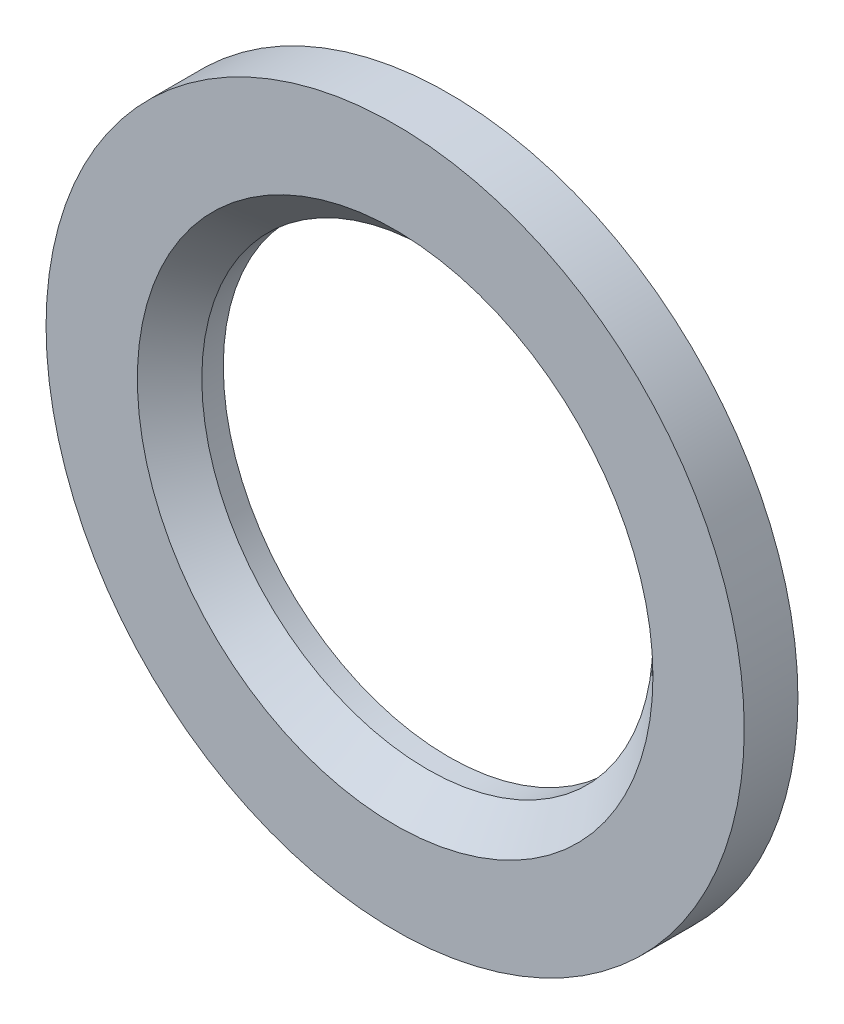
from build123d import *

# Parameters (mm, degrees)
SKETCH1_R           = 6.5
SKETCH1_R_2         = 4.2
BOSS_EXTRUDE1_DEPTH = 1
CHAMFER1_SIZE       = 0.6


with BuildPart() as part:
    # Sketch1 → Boss-Extrude1 (new body)
    with BuildSketch(Plane.XY):
        Circle(SKETCH1_R)
        Circle(SKETCH1_R_2, mode=Mode.SUBTRACT)
    extrude(amount=BOSS_EXTRUDE1_DEPTH)

    # Chamfer1
    chamfer1_edges = [part.edges().sort_by_distance(p)[0] for p in [
        (-4.2, 0, 1),
    ]]
    chamfer(chamfer1_edges, length=CHAMFER1_SIZE)


solid = part.part
